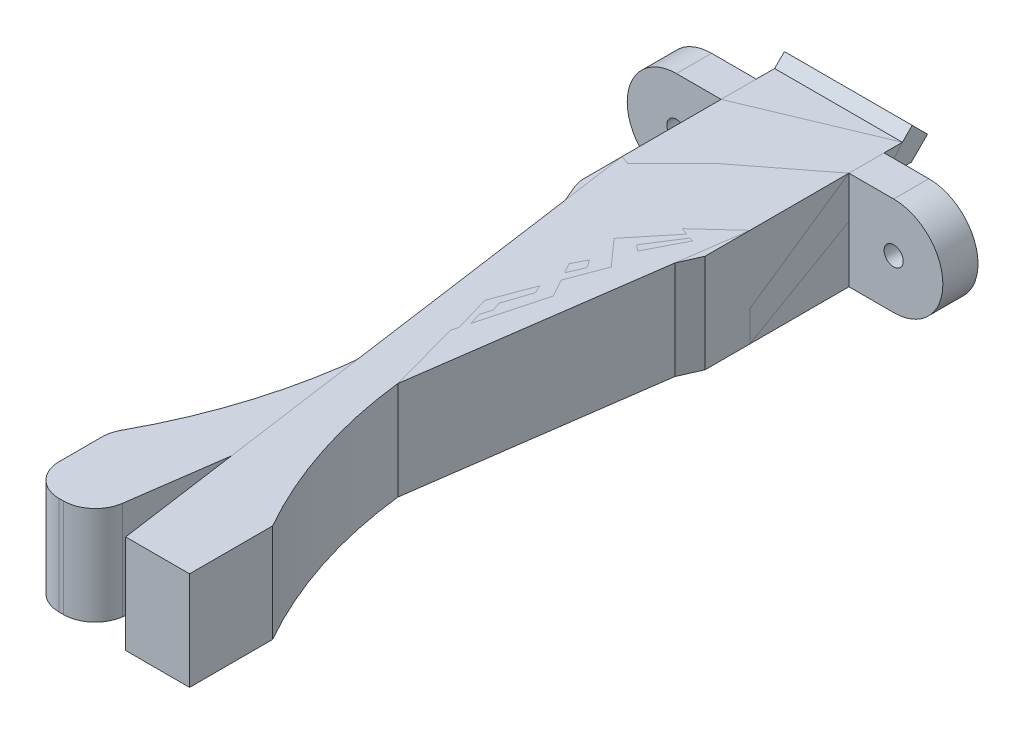
from build123d import *

# Parameters (mm, degrees)
SKETCH2_W           = 10
SKETCH2_H           = 14.768412439
BOSS_EXTRUDE1_DEPTH = 5
BOSS_EXTRUDE4_DEPTH = 10
SKETCH9_W           = 10
SKETCH9_H           = 3.18
SKETCH9_H_2         = 3.888412439
CUT_EXTRUDE3_DEPTH  = 5
BOSS_EXTRUDE5_DEPTH = 7.7
SKETCH12_R          = 0.75
BOSS_EXTRUDE7_DEPTH = 2.75
FILLET1_R           = 2.5


with BuildPart() as part:
    # Sketch2 → Boss-Extrude1 (new body)
    with BuildSketch(Plane.XY):
        with Locations((0, 1.566049366)):
            Rectangle(SKETCH2_W, SKETCH2_H)
    extrude(amount=BOSS_EXTRUDE1_DEPTH)

    # Sketch8 → Boss-Extrude4 (add)
    with BuildSketch(Plane.ZY.offset(5)):
        Polygon((-0.15, 5.770255585), (0, 5.770255585), (0, 4.070255585), (-0.15, 4.070255585), (-2.137867966, 4.070255585), (-3.402081528, 5.334469147), (-2.2, 6.536550675), (-1.43370491, 5.770255585), align=None)
        Polygon((-0.15, -1.929744415), (0, -1.929744415), (0, -0.229744415), (-0.15, -0.229744415), (-1.43370491, -0.229744415), (-2.2, 0.536550675), (-3.402081528, -0.665530853), (-2.137867966, -1.929744415), align=None)
    extrude(amount=-BOSS_EXTRUDE4_DEPTH)

    # Sketch9 → Cut-Extrude3 (cut)
    with BuildSketch(Plane(origin=(0, 0, 0), x_dir=(-1, 0, 0), z_dir=(0, 0, -1))):
        with Locations((0, 7.360255585)):
            Rectangle(SKETCH9_W, SKETCH9_H)
        with Locations((0, -3.873950635)):
            Rectangle(SKETCH9_W, SKETCH9_H_2)
    extrude(amount=-CUT_EXTRUDE3_DEPTH, mode=Mode.SUBTRACT)

    # Sketch10 → Boss-Extrude5 (add)
    with BuildSketch(Plane(origin=(0, 5.770255585, 0), x_dir=(1, 0, 0), z_dir=(0, 1, 0))):
        with BuildLine():
            Line((-5, -5), (-5, -10.5))
            Line((-5, -10.5), (1.352445729, -55.7))
            Line((1.352445729, -55.7), (6.352445729, -55.7))
            Line((6.352445729, -55.7), (6.352445729, -49.2))
            ThreePointArc((6.352445729, -49.2), (1.383429579, -31.764936646), (5, -14))
            Line((5, -14), (5, -5))
            Line((5, -5), (-5, -5))
        make_face()
    extrude(amount=-BOSS_EXTRUDE5_DEPTH)

    # Sketch12 → Boss-Extrude7 (add)
    with BuildSketch(Plane.XY):
        with BuildLine():
            Line((5, 5.770255585), (8.5, 5.770255585))
            ThreePointArc((8.5, 5.770255585), (12.35, 1.920255585), (8.5, -1.929744415))
            Line((8.5, -1.929744415), (5, -1.929744415))
            Line((5, -1.929744415), (5, 5.770255585))
        make_face()
        with Locations((8.5, 1.920255585)):
            Circle(SKETCH12_R, mode=Mode.SUBTRACT)
    extrude(amount=BOSS_EXTRUDE7_DEPTH)


with BuildPart() as body_2:
    # Mirror1: mirrored copy
    add(part.part.mirror(Plane(origin=(0, 0, 0), x_dir=(0, 0, 1), z_dir=(1, 0, 0))))

    # Fillet1
    fillet1_edges = [body_2.edges().sort_by_distance(p)[0] for p in [
        (-6.352445729, 1.920255585, 49.2),
        (-5, 1.920255585, 14),
        (-1.352445729, 1.920255585, 55.7),
        (-6.352445729, 1.920255585, 55.7),
    ]]
    fillet(fillet1_edges, radius=FILLET1_R)


solid = Compound([part.part, body_2.part])
